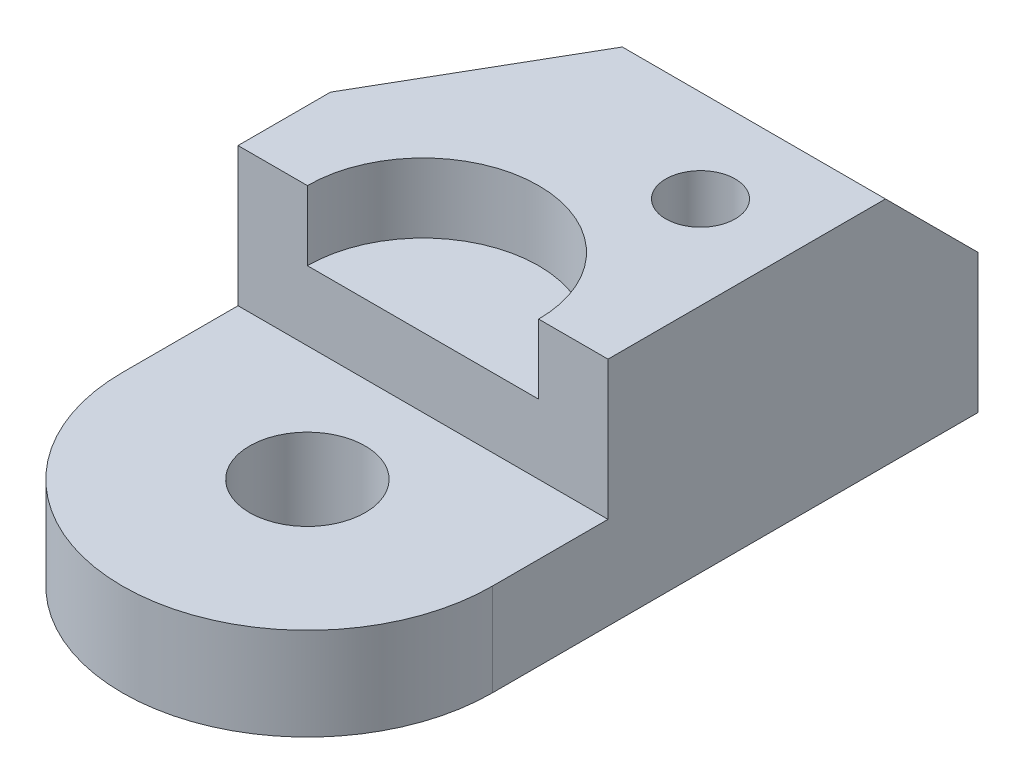
from build123d import *

# Parameters (mm, degrees)
BOSS_EXTRUDE1_DEPTH         = 25.4
BOSS_EXTRUDE2_DEPTH         = 63.5
CUT_EXTRUDE1_DEPTH          = 131.136274728
CUT_EXTRUDE1_DEPTH_BACK     = 131.136274728
F_1_4_0_75_DIAMETER_HOLE1_D = 19.05
SKETCH6_R                   = 31.75
CUT_EXTRUDE2_DEPTH          = 19.05
F_1_4_1_25_DIAMETER_HOLE1_D = 31.75


with BuildPart() as part:
    # Sketch1 → Boss-Extrude1 (new body)
    with BuildSketch(Plane(origin=(0, 0, 0), x_dir=(1, 0, 0), z_dir=(0, 1, 0))):
        with BuildLine():
            Line((50.8, 0), (-50.8, 0))
            Line((-50.8, 0), (-50.8, -31.75))
            ThreePointArc((-50.8, -31.75), (0, -82.55), (50.8, -31.75))
            Line((50.8, -31.75), (50.8, 0))
        make_face()
    extrude(amount=BOSS_EXTRUDE1_DEPTH)

    # Sketch2 → Boss-Extrude2 (add)
    with BuildSketch(Plane(origin=(0, 0, 0), x_dir=(1, 0, 0), z_dir=(0, 1, 0))):
        Polygon((-50.8, 0), (-50.8, 25.4), (-6.805909488, 101.6), (50.8, 101.6), (50.8, 0), align=None)
    extrude(amount=BOSS_EXTRUDE2_DEPTH)

    # Sketch3 → Cut-Extrude1 (cut, two sides: drawn at the far end of the back side and taken through both)
    with BuildSketch(Plane(origin=(0, 0, 0), x_dir=(0, 0, -1), z_dir=(1, 0, 0)).offset(-CUT_EXTRUDE1_DEPTH_BACK)):
        Polygon((76.2, 63.5), (101.6, 63.5), (101.6, 38.1), align=None)
    extrude(amount=CUT_EXTRUDE1_DEPTH + CUT_EXTRUDE1_DEPTH_BACK, mode=Mode.SUBTRACT)

    # 1_4 _0.75_ Diameter Hole1 (through all)
    with Locations(Plane(origin=(0, 63.5, 0), x_dir=(1, 0, 0), z_dir=(0, 1, 0))):
        with Locations((25.4, 50.8)):
            Hole(F_1_4_0_75_DIAMETER_HOLE1_D / 2)

    # Sketch6 → Cut-Extrude2 (cut)
    with BuildSketch(Plane(origin=(0, 63.5, 0), x_dir=(1, 0, 0), z_dir=(0, 1, 0))):
        Circle(SKETCH6_R)
    extrude(amount=-CUT_EXTRUDE2_DEPTH, mode=Mode.SUBTRACT)

    # 1_4 _1.25_ Diameter Hole1 (through all)
    with Locations(Plane(origin=(0, 25.4, 0), x_dir=(1, 0, 0), z_dir=(0, 1, 0))):
        with Locations((0, -31.75)):
            Hole(F_1_4_1_25_DIAMETER_HOLE1_D / 2)


solid = part.part
